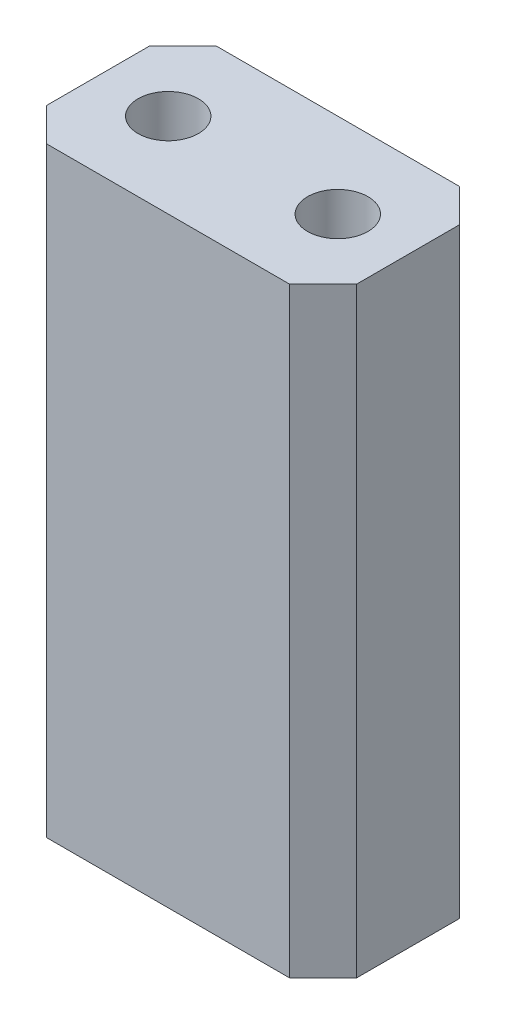
from build123d import *

# Parameters (mm, degrees)
SKETCH_1_W      = 4.64
SKETCH_1_H      = 2.54
SKETCH_1_W_2    = 0.64
SKETCH_1_H_2    = 0.64
EXTRUDE_1_DEPTH = 6
SKETCH_2_W      = 4.64
SKETCH_2_H      = 2.54
SKETCH_2_R      = 0.45254834
EXTRUDE_2_DEPTH = 3
CHAMFER_1_SIZE  = 0.5


with BuildPart() as part:
    # Эскиз1 → Бобышка-Вытянуть1 (new body)
    with BuildSketch(Plane(origin=(0, 0, 0), x_dir=(1, 0, 0), z_dir=(0, 1, 0))):
        Rectangle(SKETCH_1_W, SKETCH_1_H)
        with Locations((-1.27, 0)):
            Rectangle(SKETCH_1_W_2, SKETCH_1_H_2, mode=Mode.SUBTRACT)
        with Locations((1.27, 0)):
            Rectangle(SKETCH_1_W_2, SKETCH_1_H_2, mode=Mode.SUBTRACT)
    extrude(amount=EXTRUDE_1_DEPTH)

    # Эскиз2 → Бобышка-Вытянуть2 (add)
    with BuildSketch(Plane(origin=(0, 6, 0), x_dir=(1, 0, 0), z_dir=(0, 1, 0))):
        Rectangle(SKETCH_2_W, SKETCH_2_H)
        with Locations((-1.27, 0)):
            Circle(SKETCH_2_R, mode=Mode.SUBTRACT)
        with Locations((1.27, 0)):
            Circle(SKETCH_2_R, mode=Mode.SUBTRACT)
    extrude(amount=EXTRUDE_2_DEPTH)

    # Фаска1
    chamfer_1_edges = [part.edges().sort_by_distance(p)[0] for p in [
        (2.32, 4.5, 1.27),
        (-2.32, 4.5, 1.27),
        (-2.32, 4.5, -1.27),
        (2.32, 4.5, -1.27),
    ]]
    chamfer(chamfer_1_edges, length=CHAMFER_1_SIZE)


solid = part.part
